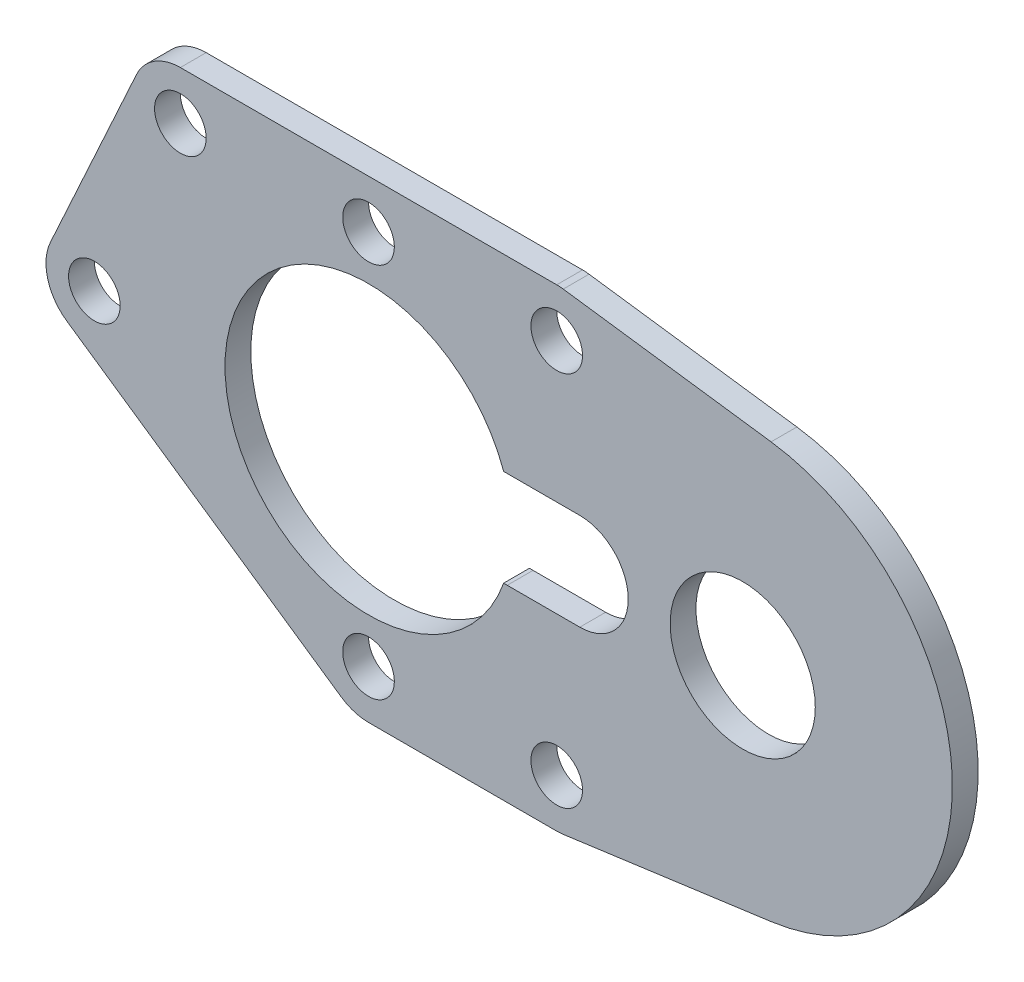
from build123d import *

# Parameters (mm, degrees)
SKETCH1_R           = 3
SKETCH1_R_2         = 4.5
SKETCH1_R_3         = 1.6
BOSS_EXTRUDE3_DEPTH = 1.6
CUT_EXTRUDE1_DEPTH  = 10
SKETCH3_R           = 8.9
CUT_EXTRUDE2_DEPTH  = 30


with BuildPart() as part:
    # Sketch1 → Boss-Extrude3 (new body)
    with BuildSketch(Plane.XY):
        with BuildLine():
            Line((12.073070054, 14.639688463), (24.958502044, 12.880515151))
            ThreePointArc((24.958502044, 12.880515151), (36.2, 0), (24.958502044, -12.880515151))
            Line((24.958502044, -12.880515151), (12.073070054, -14.639688463))
            ThreePointArc((12.073070054, -14.639688463), (11.870633815, -14.660360595), (11.66726189, -14.66726189))
            Line((11.66726189, -14.66726189), (0, -14.66726189))
            ThreePointArc((0, -14.66726189), (-0.888679088, -14.53261518), (-1.697586366, -14.140761542))
            Line((-1.697586366, -14.140761542), (-18.697586366, -2.473499652))
            ThreePointArc((-18.697586366, -2.473499652), (-19.891071988, -0.801063519), (-19.728500117, 1.247111507))
            Line((-19.728500117, 1.247111507), (-14.395762007, 12.914373397))
            ThreePointArc((-14.395762007, 12.914373397), (-13.288783625, 14.191279968), (-11.66726189, 14.66726189))
            Line((-11.66726189, 14.66726189), (11.66726189, 14.66726189))
            ThreePointArc((11.66726189, 14.66726189), (11.870633815, 14.660360595), (12.073070054, 14.639688463))
        make_face()
        Circle(SKETCH1_R, mode=Mode.SUBTRACT)
        with Locations((23.2, 0)):
            Circle(SKETCH1_R_2, mode=Mode.SUBTRACT)
        with Locations((8.6, 0)):
            Circle(SKETCH1_R, mode=Mode.SUBTRACT)
        with Locations((-17, 0)):
            Circle(SKETCH1_R_3, mode=Mode.SUBTRACT)
        with Locations((0, -11.66726189)):
            Circle(SKETCH1_R_3, mode=Mode.SUBTRACT)
        with Locations((11.66726189, -11.66726189)):
            Circle(SKETCH1_R_3, mode=Mode.SUBTRACT)
        with Locations((-11.66726189, 11.66726189)):
            Circle(SKETCH1_R_3, mode=Mode.SUBTRACT)
        with Locations((0, 11.66726189)):
            Circle(SKETCH1_R_3, mode=Mode.SUBTRACT)
        with Locations((11.66726189, 11.66726189)):
            Circle(SKETCH1_R_3, mode=Mode.SUBTRACT)
    extrude(amount=BOSS_EXTRUDE3_DEPTH)

    # Sketch2 → Cut-Extrude1 (cut)
    with BuildSketch(Plane.XY.offset(1.6)):
        with BuildLine():
            Line((8.6, 3), (13.1, 3))
            ThreePointArc((13.1, 3), (16.1, 0), (13.1, -3))
            Line((13.1, -3), (8.6, -3))
            ThreePointArc((8.6, -3), (5.6, 0), (8.6, 3))
        make_face()
    extrude(amount=-CUT_EXTRUDE1_DEPTH, mode=Mode.SUBTRACT)

    # Sketch3 → Cut-Extrude2 (cut)
    with BuildSketch(Plane.XY.offset(1.6)):
        Circle(SKETCH3_R)
    extrude(amount=-CUT_EXTRUDE2_DEPTH, mode=Mode.SUBTRACT)


solid = part.part
